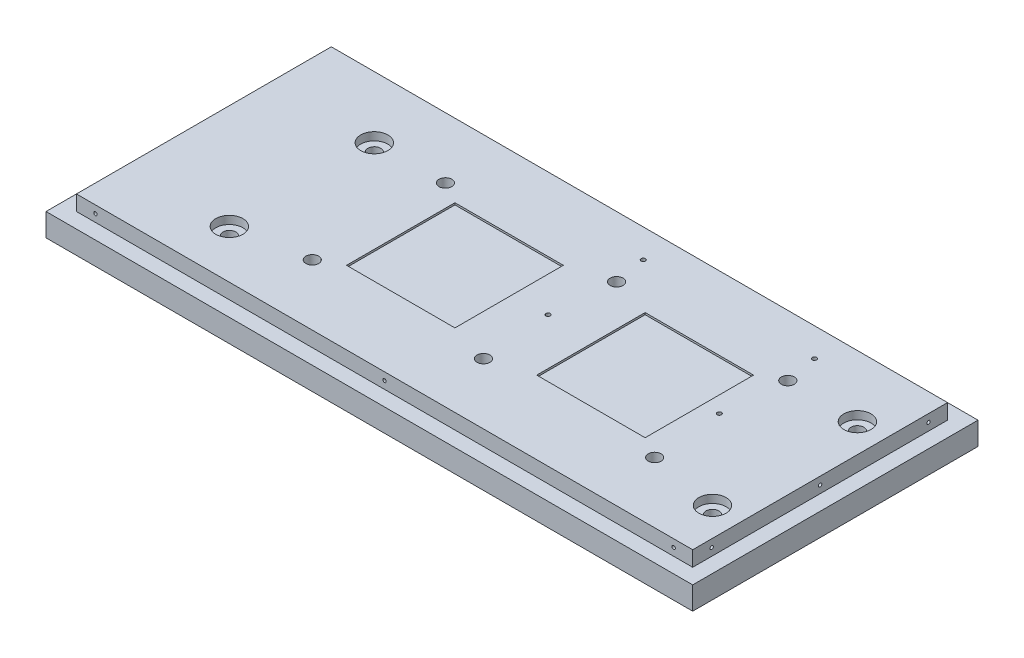
from build123d import *

# Parameters (mm, degrees)
SKETCH1_W                                            = 340
SKETCH1_H                                            = 150
BOSS_EXTRUDE1_DEPTH                                  = 20
LASERCAVITYMOUNTINGHOLE_CBORE_FOR_1_4_SO_D           = 6.7564
LASERCAVITYMOUNTINGHOLE_CBORE_FOR_1_4_SO_CBORE_D     = 11.1125
LASERCAVITYMOUNTINGHOLE_CBORE_FOR_1_4_SO_CBORE_DEPTH = 6.35
SKETCH5_W                                            = 57
SKETCH5_H                                            = 57
TEC_GROOVE_DEPTH                                     = 1
SKETCH6_W                                            = 340
SKETCH6_H                                            = 8
WALL1_DEPTH                                          = 8
SKETCH7_W                                            = 142
SKETCH7_H                                            = 8
WALL2_DEPTH                                          = 8
SKETCH9_W                                            = 332
SKETCH9_H                                            = 8
WALL3_DEPTH                                          = 8
SKETCH10_W                                           = 134
SKETCH10_H                                           = 8
WALL4_DEPTH                                          = 8
F_2_56_TAPPED_HOLE1_D                                = 1.778
F_2_56_TAPPED_HOLE1_DEPTH                            = 15
F_2_56_TAPPED_HOLE1_TIP                              = 0.53416509
F_2_56_TAPPED_HOLE2_D                                = 1.778
F_2_56_TAPPED_HOLE2_DEPTH                            = 15
F_2_56_TAPPED_HOLE2_TIP                              = 0.53416509
F_2_56_TAPPED_HOLE3_D                                = 1.778
F_2_56_TAPPED_HOLE3_DEPTH                            = 15
F_2_56_TAPPED_HOLE3_TIP                              = 0.53416509
ELECTRONICBOARDMOUNTING_D                            = 2.2606
ELECTRONICBOARDMOUNTING_DEPTH                        = 20
ELECTRONICBOARDMOUNTING_TIP                          = 0.679152758
F_2_56_TAPPED_HOLE4_D                                = 1.778
F_2_56_TAPPED_HOLE4_DEPTH                            = 15
F_2_56_TAPPED_HOLE4_TIP                              = 0.53416509
OPTICALTABLEMOUNTINGHOLES_CBORE_FOR_1_4_D            = 6.7564
OPTICALTABLEMOUNTINGHOLES_CBORE_FOR_1_4_DEPTH        = 20
OPTICALTABLEMOUNTINGHOLES_CBORE_FOR_1_4_CBORE_D      = 14.2875
OPTICALTABLEMOUNTINGHOLES_CBORE_FOR_1_4_CBORE_DEPTH  = 4.191
OPTICALTABLEMOUNTINGHOLES_CBORE_FOR_1_4_TIP          = 2.029827343


with BuildPart() as part:
    # Sketch1 → Boss-Extrude1 (new body)
    with BuildSketch(Plane(origin=(0, 0, 0), x_dir=(1, 0, 0), z_dir=(0, 1, 0))):
        with Locations((170, 75)):
            Rectangle(SKETCH1_W, SKETCH1_H)
    extrude(amount=BOSS_EXTRUDE1_DEPTH)

    # LaserCavityMountingHole_CBORE for 1/4 Socket Head Cap Screw1 (through all)
    with Locations(Plane(origin=(0, 0, 0), x_dir=(-1, 0, 0), z_dir=(0, -1, 0))):
        with Locations((-100, 40), (-190, 40), (-280, 40), (-280, 110), (-190, 110), (-100, 110)):
            CounterBoreHole(LASERCAVITYMOUNTINGHOLE_CBORE_FOR_1_4_SO_D / 2, LASERCAVITYMOUNTINGHOLE_CBORE_FOR_1_4_SO_CBORE_D / 2, LASERCAVITYMOUNTINGHOLE_CBORE_FOR_1_4_SO_CBORE_DEPTH)

    # Sketch5 → TEC_groove (cut)
    with BuildSketch(Plane(origin=(0, 20, 0), x_dir=(1, 0, 0), z_dir=(0, 1, 0))):
        with Locations((140, 75)):
            Rectangle(SKETCH5_W, SKETCH5_H)
        with Locations((240, 75)):
            Rectangle(SKETCH5_W, SKETCH5_H)
    extrude(amount=-TEC_GROOVE_DEPTH, mode=Mode.SUBTRACT)

    # Sketch6 → Wall1 (cut)
    with BuildSketch(Plane.XY):
        with Locations((170, 16)):
            Rectangle(SKETCH6_W, SKETCH6_H)
    extrude(amount=-WALL1_DEPTH, mode=Mode.SUBTRACT)

    # Sketch7 → Wall2 (cut)
    with BuildSketch(Plane(origin=(340, 0, 0), x_dir=(0, 0, -1), z_dir=(1, 0, 0))):
        with Locations((79, 16)):
            Rectangle(SKETCH7_W, SKETCH7_H)
    extrude(amount=-WALL2_DEPTH, mode=Mode.SUBTRACT)

    # Sketch9 → Wall3 (cut)
    with BuildSketch(Plane(origin=(0, 0, -150), x_dir=(-1, 0, 0), z_dir=(0, 0, -1))):
        with Locations((-166, 16)):
            Rectangle(SKETCH9_W, SKETCH9_H)
    extrude(amount=-WALL3_DEPTH, mode=Mode.SUBTRACT)

    # Sketch10 → Wall4 (cut)
    with BuildSketch(Plane.ZY):
        with Locations((-75, 16)):
            Rectangle(SKETCH10_W, SKETCH10_H)
    extrude(amount=-WALL4_DEPTH, mode=Mode.SUBTRACT)

    # #2-56 Tapped Hole1
    with Locations(Plane.XY.offset(-8)):
        with Locations((18, 16), (322, 16), (170, 16)):
            Hole(F_2_56_TAPPED_HOLE1_D / 2, depth=F_2_56_TAPPED_HOLE1_DEPTH)
            with Locations((0, 0, -(F_2_56_TAPPED_HOLE1_DEPTH + F_2_56_TAPPED_HOLE1_TIP / 2))):  # 118° drill point
                Cone(0, F_2_56_TAPPED_HOLE1_D / 2, F_2_56_TAPPED_HOLE1_TIP, mode=Mode.SUBTRACT)

    # #2-56 Tapped Hole2
    with Locations(Plane(origin=(8, 16, -132), x_dir=(0, 0, -1), z_dir=(-1, 0, 0))):
        with Locations((0, 0), (-114, 0), (-57, 0)):
            Hole(F_2_56_TAPPED_HOLE2_D / 2, depth=F_2_56_TAPPED_HOLE2_DEPTH)
            with Locations((0, 0, -(F_2_56_TAPPED_HOLE2_DEPTH + F_2_56_TAPPED_HOLE2_TIP / 2))):  # 118° drill point
                Cone(0, F_2_56_TAPPED_HOLE2_D / 2, F_2_56_TAPPED_HOLE2_TIP, mode=Mode.SUBTRACT)

    # #2-56 Tapped Hole3
    with Locations(Plane(origin=(0, 0, -142), x_dir=(-1, 0, 0), z_dir=(0, 0, -1))):
        with Locations((-322, 16), (-18, 16), (-170, 16)):
            Hole(F_2_56_TAPPED_HOLE3_D / 2, depth=F_2_56_TAPPED_HOLE3_DEPTH)
            with Locations((0, 0, -(F_2_56_TAPPED_HOLE3_DEPTH + F_2_56_TAPPED_HOLE3_TIP / 2))):  # 118° drill point
                Cone(0, F_2_56_TAPPED_HOLE3_D / 2, F_2_56_TAPPED_HOLE3_TIP, mode=Mode.SUBTRACT)

    # ElectronicBoardMounting
    with Locations(Plane(origin=(0, 20, 0), x_dir=(1, 0, 0), z_dir=(0, 1, 0))):
        with Locations((187, 127), (277, 127), (277, 77), (187, 77)):
            Hole(ELECTRONICBOARDMOUNTING_D / 2, depth=ELECTRONICBOARDMOUNTING_DEPTH)
            with Locations((0, 0, -(ELECTRONICBOARDMOUNTING_DEPTH + ELECTRONICBOARDMOUNTING_TIP / 2))):  # 118° drill point
                Cone(0, ELECTRONICBOARDMOUNTING_D / 2, ELECTRONICBOARDMOUNTING_TIP, mode=Mode.SUBTRACT)

    # #2-56 Tapped Hole4
    with Locations(Plane(origin=(332, 0, 0), x_dir=(0, 0, -1), z_dir=(1, 0, 0))):
        with Locations((18, 16), (132, 16), (75, 16)):
            Hole(F_2_56_TAPPED_HOLE4_D / 2, depth=F_2_56_TAPPED_HOLE4_DEPTH)
            with Locations((0, 0, -(F_2_56_TAPPED_HOLE4_DEPTH + F_2_56_TAPPED_HOLE4_TIP / 2))):  # 118° drill point
                Cone(0, F_2_56_TAPPED_HOLE4_D / 2, F_2_56_TAPPED_HOLE4_TIP, mode=Mode.SUBTRACT)

    # OpticalTableMountingHoles_CBORE for 1/4 Binding Head Machine Screw1
    with Locations(Plane(origin=(0, 20, 0), x_dir=(1, 0, 0), z_dir=(0, 1, 0))):
        with Locations((63, 109.6), (317, 109.6), (317, 33.4), (63, 33.4)):
            CounterBoreHole(OPTICALTABLEMOUNTINGHOLES_CBORE_FOR_1_4_D / 2, OPTICALTABLEMOUNTINGHOLES_CBORE_FOR_1_4_CBORE_D / 2, OPTICALTABLEMOUNTINGHOLES_CBORE_FOR_1_4_CBORE_DEPTH, depth=OPTICALTABLEMOUNTINGHOLES_CBORE_FOR_1_4_DEPTH)
            with Locations((0, 0, -(OPTICALTABLEMOUNTINGHOLES_CBORE_FOR_1_4_DEPTH + OPTICALTABLEMOUNTINGHOLES_CBORE_FOR_1_4_TIP / 2))):  # 118° drill point
                Cone(0, OPTICALTABLEMOUNTINGHOLES_CBORE_FOR_1_4_D / 2, OPTICALTABLEMOUNTINGHOLES_CBORE_FOR_1_4_TIP, mode=Mode.SUBTRACT)


solid = part.part
